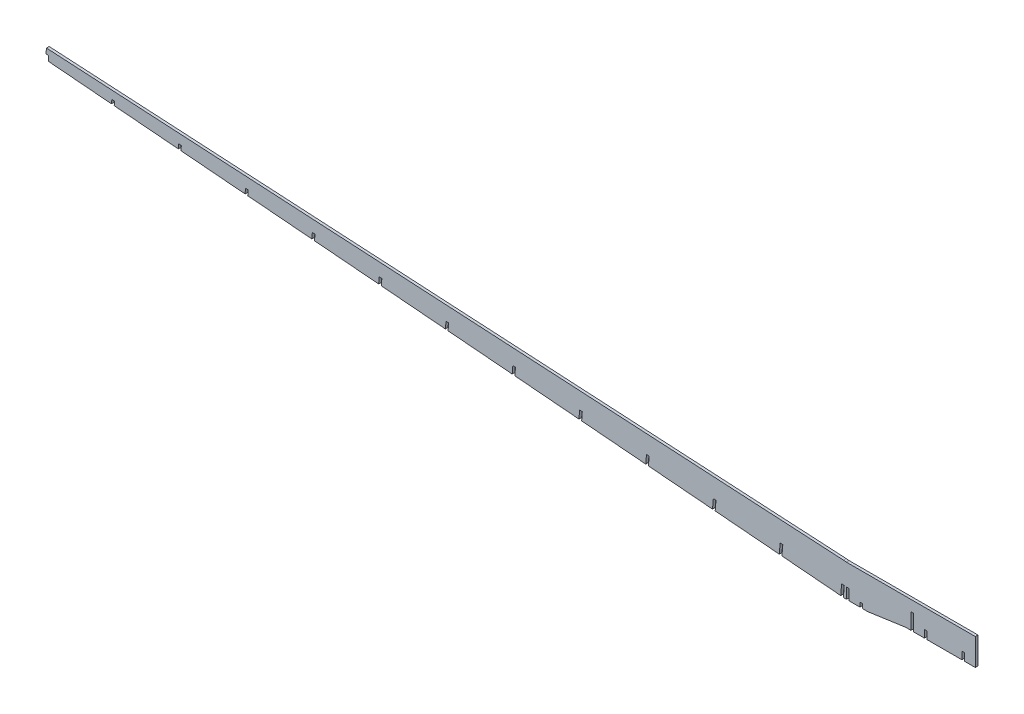
from build123d import *

# Parameters (mm, degrees)
BOSS_EXTRUDE1_DEPTH = 1.5875
CUT_EXTRUDE1_DEPTH  = 4.175


with BuildPart() as part:
    # Sketch1 → Boss-Extrude1 (new body, symmetric)
    with BuildSketch(Plane.XY):
        Polygon((76.2, 37.697541537), (76.2, 56.747541537), (79.375, 56.747541537), (79.375, 37.697541537), (92.075, 37.697541537), (92.075, 46.587541537), (95.25, 46.587541537), (95.25, 37.697541537), (136.525, 37.697541537), (136.525, 46.587541537), (139.7, 46.587541537), (139.7, 37.697541537), (152.4, 37.697541537), (152.4, 69.447541537), (0, 69.447541537), (-0.423998633, 69.491926731), (-3.587863461, 69.757603883), (-946.051908629, 122.953392794), (-946.583462345, 116.623288424), (-943.412318182, 116.444298555), (-943.91275138, 110.48479854), (-6.775989292, 31.791225946), (-5.713280681, 44.446685258), (-2.549415853, 44.181008106), (-3.612124464, 31.525548794), (-1.492292584, 31.347541537), (0, 31.347541537), (0, 44.047541537), (3.175, 44.047541537), (3.175, 31.347541537), (15.875, 31.347541537), (15.875, 36.427541537), (19.05, 36.427541537), (19.05, 31.347541537), (25.4, 31.347541537), (69.85, 37.697541537), align=None)
    extrude(amount=BOSS_EXTRUDE1_DEPTH, both=True)

    # Sketch2 → Cut-Extrude1 (cut, through all)
    with BuildSketch(Plane.XY.offset(1.5875)):
        Polygon((-76.254460917, 37.625496217), (-75.245037036, 49.646404609), (-78.411328309, 49.883186), (-79.418325745, 37.891173369), align=None)
        Polygon((-155.224527027, 44.256797945), (-154.27566721, 55.556468134), (-157.441958483, 55.793249525), (-158.388391855, 44.522475098), align=None)
        Polygon((-234.194593137, 50.888099674), (-233.306297384, 61.466531659), (-236.472588657, 61.70331305), (-237.358457965, 51.153776826), align=None)
        Polygon((-313.164659247, 57.519401402), (-312.336927558, 67.376595183), (-315.503218831, 67.613376574), (-316.328524075, 57.785078555), align=None)
        Polygon((-392.134725356, 64.15070313), (-391.367557732, 73.286658708), (-394.533849005, 73.523440099), (-395.298590185, 64.416380283), align=None)
        Polygon((-471.104791466, 70.782004859), (-470.398187906, 79.196722233), (-473.564479179, 79.433503624), (-474.268656294, 71.047682011), align=None)
        Polygon((-550.074857576, 77.413306587), (-549.42881808, 85.106785757), (-552.595109353, 85.343567149), (-553.238722404, 77.67898374), align=None)
        Polygon((-629.044923686, 84.044608316), (-628.459448254, 91.016849282), (-631.625739527, 91.253630673), (-632.208788514, 84.310285468), align=None)
        Polygon((-708.014989796, 90.675910044), (-707.490078428, 96.926912807), (-710.656369701, 97.163694198), (-711.178854624, 90.941587197), align=None)
        Polygon((-786.985055905, 97.307211772), (-786.520708602, 102.836976331), (-789.686999875, 103.073757723), (-790.148920734, 97.572888925), align=None)
        Polygon((-865.955122015, 103.938513501), (-865.551338776, 108.747039856), (-868.717630049, 108.983821247), (-869.118986843, 104.204190653), align=None)
    extrude(amount=-CUT_EXTRUDE1_DEPTH, mode=Mode.SUBTRACT)


solid = part.part
